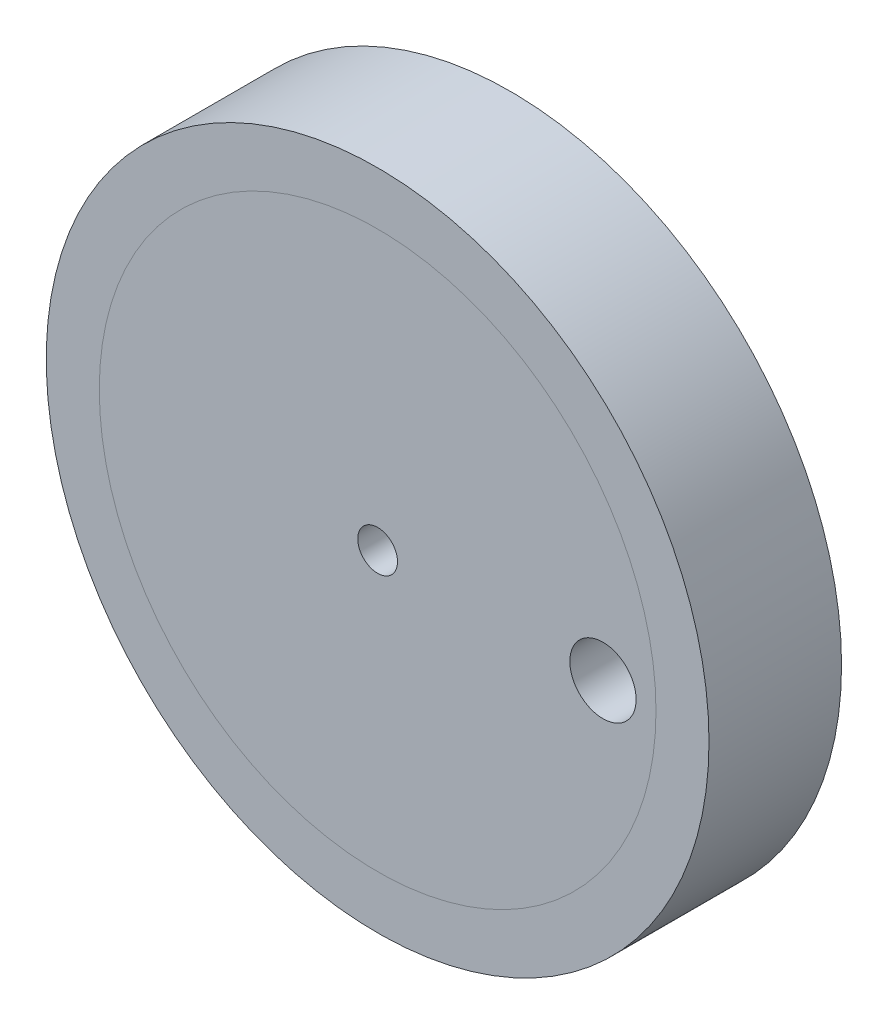
from build123d import *

# Parameters (mm, degrees)
SKETCH1_R           = 25
BOSS_EXTRUDE1_DEPTH = 10
SKETCH3_R           = 21
BOSS_EXTRUDE2_DEPTH = 10.0001
SKETCH4_R           = 21
SKETCH4_R_2         = 1.5
SKETCH4_R_3         = 2.5
BOSS_EXTRUDE3_DEPTH = 10


with BuildPart() as part:
    # Sketch1 → Boss-Extrude1 (new body)
    with BuildSketch(Plane.XY):
        with Locations((-26.126616779, 11.26147275)):
            Circle(SKETCH1_R)
    extrude(amount=BOSS_EXTRUDE1_DEPTH)


with BuildPart() as body_2:
    # Sketch3 → Boss-Extrude2 (new body)
    with BuildSketch(Plane.XY.offset(10)):
        with Locations((-26.126616779, 11.26147275)):
            Circle(SKETCH3_R)
    extrude(amount=-BOSS_EXTRUDE2_DEPTH)


with BuildPart() as part_1:
    add(part.part)

    # Combine1: cut body 2
    add(body_2.part, mode=Mode.SUBTRACT)


with BuildPart() as body_2_2:
    # Sketch4 → Boss-Extrude3 (new body)
    with BuildSketch(Plane(origin=(0, 0, 0), x_dir=(-1, 0, 0), z_dir=(0, 0, -1))):
        with Locations((26.126616779, 11.26147275)):
            Circle(SKETCH4_R)
        with Locations((26.126616779, 11.26147275)):
            Circle(SKETCH4_R_2, mode=Mode.SUBTRACT)
        with Locations((9.126616779, 11.26147275)):
            Circle(SKETCH4_R_3, mode=Mode.SUBTRACT)
    extrude(amount=-BOSS_EXTRUDE3_DEPTH)


solid = Compound([part_1.part, body_2_2.part])
